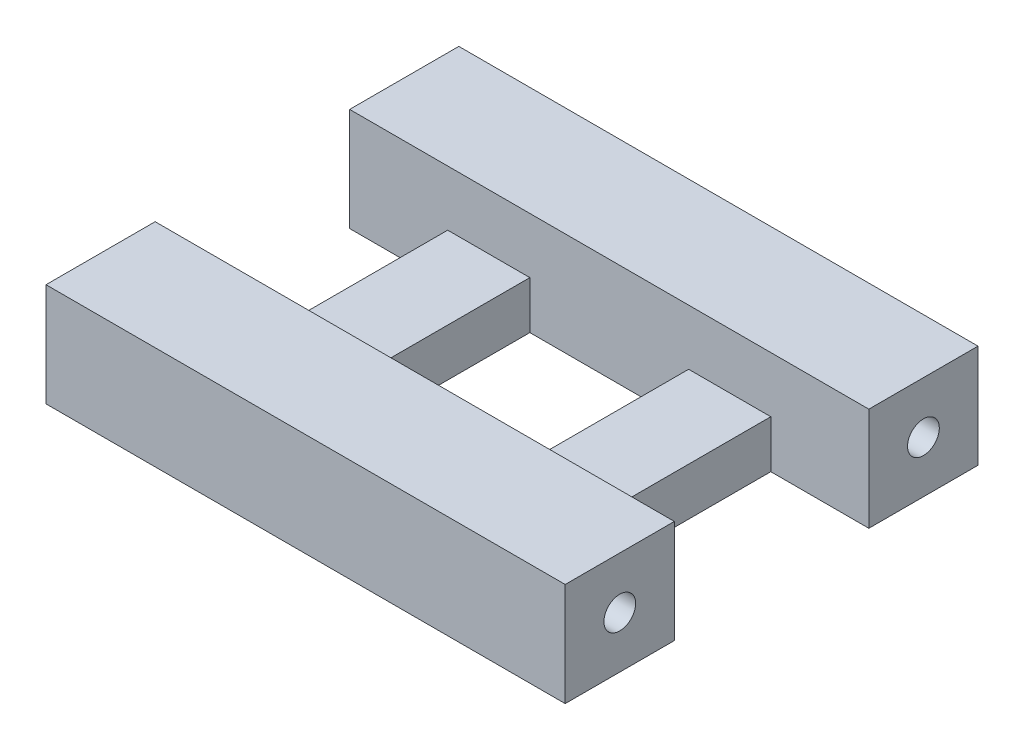
from build123d import *

# Parameters (mm, degrees)
CROQUIS1_W              = 10
CROQUIS1_H              = 12.25
SALIENTE_EXTRUIR1_DEPTH = 6.5
CROQUIS3_R              = 1
CROQUIS3_W              = 12.25
CROQUIS3_H              = 3.5
CORTAR_EXTRUIR1_DEPTH   = 35.4


with BuildPart() as part:
    # Croquis1 → Saliente-Extruir1 (new body)
    with BuildSketch(Plane(origin=(0, 0, 0), x_dir=(1, 0, 0), z_dir=(0, 1, 0))):
        Polygon((-15.606807411, 13.619327476), (-15.606807411, 6.744327476), (-9.43180722, 6.744327476), (-9.43180722, -5.505672524), (-15.606807411, -5.505672524), (-15.606807411, -12.380672524), (17.093193352, -12.380672524), (17.093193352, -5.505672524), (10.918193161, -5.505672524), (10.918193161, 6.744327476), (17.093193352, 6.744327476), (17.093193352, 13.619327476), align=None)
        with Locations((0.743192971, 0.619327476)):
            Rectangle(CROQUIS1_W, CROQUIS1_H, mode=Mode.SUBTRACT)
    extrude(amount=SALIENTE_EXTRUIR1_DEPTH)

    # Croquis3 → Cortar-Extruir1 (cut)
    with BuildSketch(Plane.ZY.offset(15.606807411)):
        with Locations((-10.181827476, 3.25)):
            Circle(CROQUIS3_R)
        with Locations((8.943172524, 3.25)):
            Circle(CROQUIS3_R)
        with Locations((-0.619327476, 4.75)):
            Rectangle(CROQUIS3_W, CROQUIS3_H)
    extrude(amount=-CORTAR_EXTRUIR1_DEPTH, mode=Mode.SUBTRACT)


solid = part.part
